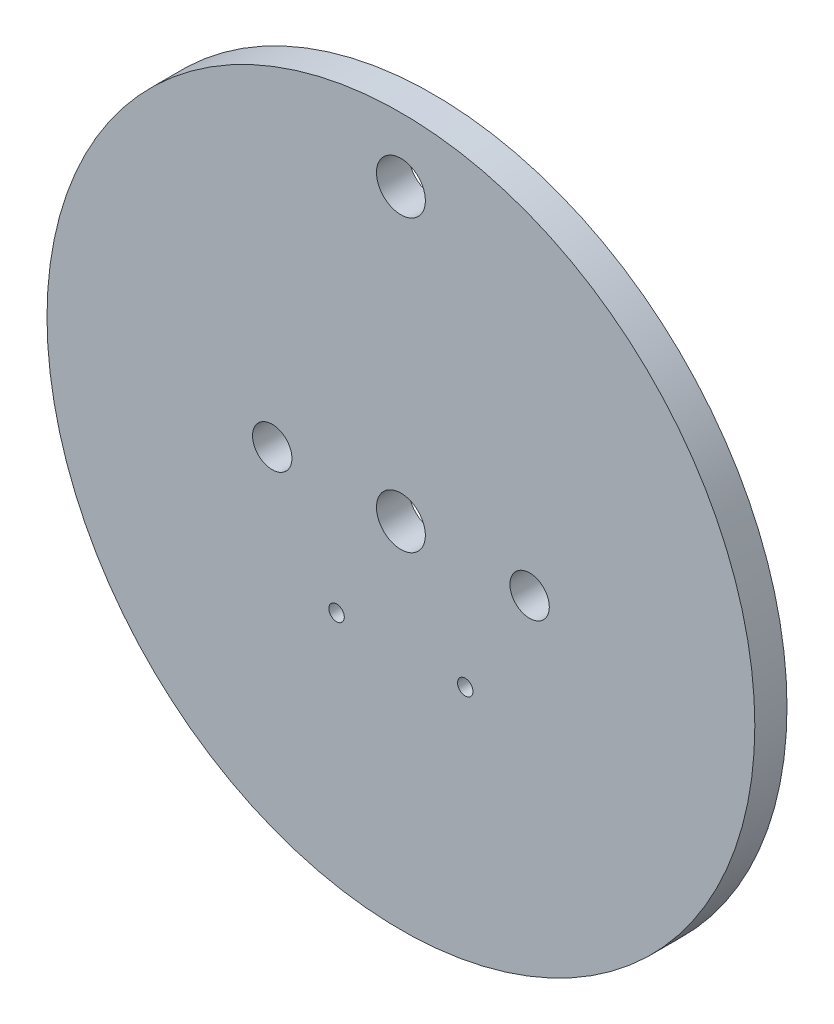
from build123d import *

# Parameters (mm, degrees)
SKETCH1_R           = 34.925
BOSS_EXTRUDE1_DEPTH = 3.175
CUT_EXTRUDE1_REACH  = 5.175
SKETCH2_R           = 2.413
CUT_EXTRUDE2_REACH  = 5.175
SKETCH4_R           = 1.9431
SKETCH4_R_2         = 0.762


with BuildPart() as part:
    # Sketch1 → Boss-Extrude1 (new body)
    with BuildSketch(Plane.XY):
        with Locations((67.638168, -28.60314574)):
            Circle(SKETCH1_R)
    extrude(amount=BOSS_EXTRUDE1_DEPTH)

    # Sketch2 → Cut-Extrude1 (cut, up to next)
    with BuildSketch(Plane.XY.offset(3.175), mode=Mode.PRIVATE) as cut_extrude1_sk1:
        with Locations((67.638168, 0)):
            Circle(SKETCH2_R)
    cut_extrude1_tool1 = extrude(cut_extrude1_sk1.sketch, amount=-CUT_EXTRUDE1_REACH, mode=Mode.PRIVATE) & part.part
    add(cut_extrude1_tool1.solids().sort_by_distance((67.638168, 0, 3.175))[0], mode=Mode.SUBTRACT)
    # Sketch2 → Cut-Extrude1 (cut, up to next)
    with BuildSketch(Plane.XY.offset(3.175), mode=Mode.PRIVATE) as cut_extrude1_sk2:
        with Locations((67.638168, -28.60314574)):
            Circle(SKETCH2_R)
    cut_extrude1_tool2 = extrude(cut_extrude1_sk2.sketch, amount=-CUT_EXTRUDE1_REACH, mode=Mode.PRIVATE) & part.part
    add(cut_extrude1_tool2.solids().sort_by_distance((67.638168, -28.603146, 3.175))[0], mode=Mode.SUBTRACT)

    # Sketch4 → Cut-Extrude2 (cut, up to next)
    with BuildSketch(Plane.XY.offset(3.175), mode=Mode.PRIVATE) as cut_extrude2_sk1:
        with Locations((54.938168, -28.60314574)):
            Circle(SKETCH4_R)
    cut_extrude2_tool1 = extrude(cut_extrude2_sk1.sketch, amount=-CUT_EXTRUDE2_REACH, mode=Mode.PRIVATE) & part.part
    add(cut_extrude2_tool1.solids().sort_by_distance((54.938168, -28.603146, 3.175))[0], mode=Mode.SUBTRACT)
    # Sketch4 → Cut-Extrude2 (cut, up to next)
    with BuildSketch(Plane.XY.offset(3.175), mode=Mode.PRIVATE) as cut_extrude2_sk2:
        with Locations((61.288168, -39.601668368)):
            Circle(SKETCH4_R_2)
    cut_extrude2_tool2 = extrude(cut_extrude2_sk2.sketch, amount=-CUT_EXTRUDE2_REACH, mode=Mode.PRIVATE) & part.part
    add(cut_extrude2_tool2.solids().sort_by_distance((61.288168, -39.601668, 3.175))[0], mode=Mode.SUBTRACT)
    # Sketch4 → Cut-Extrude2 (cut, up to next)
    with BuildSketch(Plane.XY.offset(3.175), mode=Mode.PRIVATE) as cut_extrude2_sk3:
        with Locations((80.338168, -28.60314574)):
            Circle(SKETCH4_R)
    cut_extrude2_tool3 = extrude(cut_extrude2_sk3.sketch, amount=-CUT_EXTRUDE2_REACH, mode=Mode.PRIVATE) & part.part
    add(cut_extrude2_tool3.solids().sort_by_distance((80.338168, -28.603146, 3.175))[0], mode=Mode.SUBTRACT)
    # Sketch4 → Cut-Extrude2 (cut, up to next)
    with BuildSketch(Plane.XY.offset(3.175), mode=Mode.PRIVATE) as cut_extrude2_sk4:
        with Locations((73.988168, -39.601668368)):
            Circle(SKETCH4_R_2)
    cut_extrude2_tool4 = extrude(cut_extrude2_sk4.sketch, amount=-CUT_EXTRUDE2_REACH, mode=Mode.PRIVATE) & part.part
    add(cut_extrude2_tool4.solids().sort_by_distance((73.988168, -39.601668, 3.175))[0], mode=Mode.SUBTRACT)


solid = part.part
